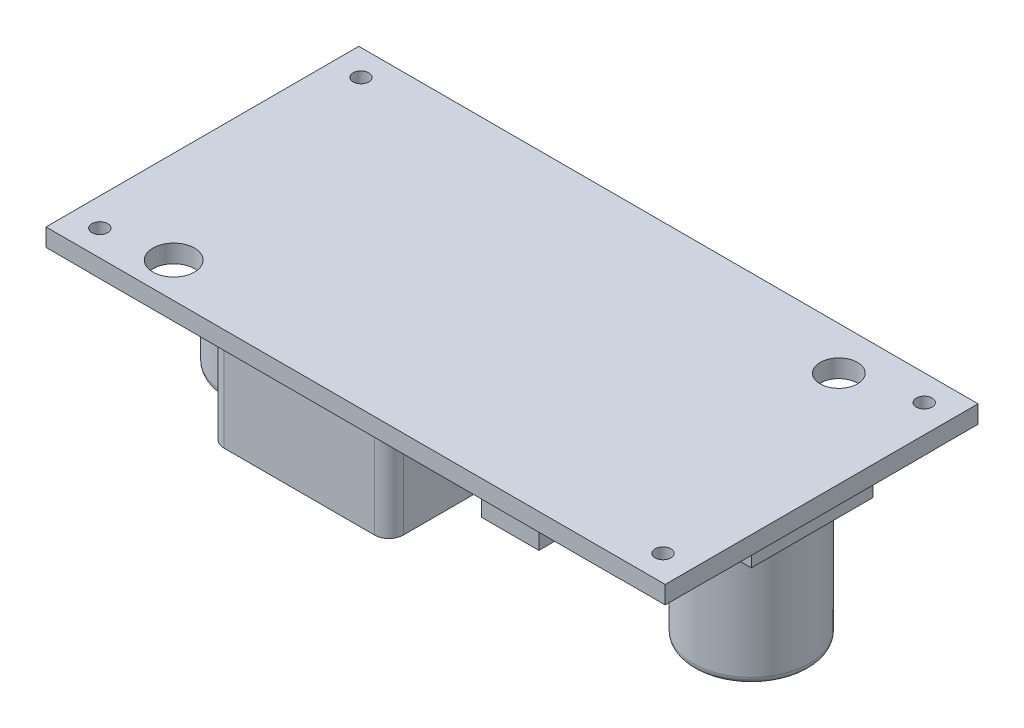
from build123d import *
from OCP.BRepFilletAPI import BRepFilletAPI_MakeChamfer

# Parameters (mm, degrees)
SKETCH1_W            = 43.15
SKETCH1_H            = 21.8
BOSS_EXTRUDE1_DEPTH  = 1.25
SKETCH2_R            = 0.55
CUT_EXTRUDE1_DEPTH   = 25.204403009
SKETCH3_R            = 1.3
SKETCH3_R_2          = 1.45
CUT_EXTRUDE2_DEPTH   = 25.204403009
SKETCH4_W            = 3
SKETCH4_H            = 3
CUT_EXTRUDE3_DEPTH   = 0.01
SKETCH5_W            = 0.089743589
SKETCH5_H            = 1
SKETCH5_W_2          = 0.384615385
SKETCH5_H_2          = 0.102564102
CUT_EXTRUDE4_DEPTH   = 0.01
SKETCH6_W            = 8.5
SKETCH6_H            = 8.5
BOSS_EXTRUDE2_DEPTH  = 1.75
SKETCH7_R            = 4.05
BOSS_EXTRUDE3_DEPTH  = 8.5
FILLET1_R            = 0.5
SKETCH8_W            = 12.5
SKETCH8_H            = 12.5
BOSS_EXTRUDE4_DEPTH  = 7.1
FILLET2_R            = 1
BOSS_EXTRUDE5_DEPTH  = 10
SKETCH10_W           = 4
SKETCH10_H           = 2.5
BOSS_EXTRUDE6_DEPTH  = 2.3
SKETCH11_W           = 10
SKETCH11_H           = 8.4
BOSS_EXTRUDE7_DEPTH  = 4.3
CHAMFER1_SIZE        = 2
CHAMFER1_SIZE2       = 0.727940469
SKETCH12_W           = 10
SKETCH12_H           = 1.5
BOSS_EXTRUDE8_DEPTH  = 1
SKETCH13_W           = 1
SKETCH13_H           = 5
BOSS_EXTRUDE9_DEPTH  = 1
LPATTERN1_COUNT      = 5
LPATTERN1_PITCH      = 1.9
SKETCH14_R           = 1.15
BOSS_EXTRUDE10_DEPTH = 1.6


with BuildPart() as part:
    # Sketch1 → Boss-Extrude1 (new body)
    with BuildSketch(Plane(origin=(0, 0, 0), x_dir=(1, 0, 0), z_dir=(0, 1, 0))):
        Rectangle(SKETCH1_W, SKETCH1_H)
    extrude(amount=BOSS_EXTRUDE1_DEPTH)

    # Sketch2 → Cut-Extrude1 (cut, through all)
    with BuildSketch(Plane(origin=(0, 1.25, 0), x_dir=(1, 0, 0), z_dir=(0, 1, 0))):
        with Locations(Location((19.625, 9.1, 0), (0, 0, 270))):
            Circle(SKETCH2_R)
        with Locations(Location((19.625, -9.1, 0), (0, 0, 270))):
            Circle(SKETCH2_R)
        with Locations(Location((-19.625, 9.1, 0), (0, 0, 270))):
            Circle(SKETCH2_R)
        with Locations(Location((-19.625, -9.1, 0), (0, 0, 270))):
            Circle(SKETCH2_R)
    extrude(amount=-CUT_EXTRUDE1_DEPTH, mode=Mode.SUBTRACT)

    # Sketch3 → Cut-Extrude2 (cut, through all)
    with BuildSketch(Plane(origin=(0, 1.25, 0), x_dir=(1, 0, 0), z_dir=(0, 1, 0))):
        with Locations(Location((14.875, 7.9, 0), (0, 0, 270))):
            Circle(SKETCH3_R)
        with Locations(Location((-15.125, -8.45, 0), (0, 0, 270))):
            Circle(SKETCH3_R_2)
    extrude(amount=-CUT_EXTRUDE2_DEPTH, mode=Mode.SUBTRACT)

    # Sketch4 → Cut-Extrude3 (cut)
    with BuildSketch(Plane.XZ):
        with Locations((20.075, -9.4)):
            Rectangle(SKETCH4_W, SKETCH4_H)
        with Locations((20.075, 9.4)):
            Rectangle(SKETCH4_W, SKETCH4_H)
        with Locations((-20.075, 9.4)):
            Rectangle(SKETCH4_W, SKETCH4_H)
        with Locations((-20.075, -9.4)):
            Rectangle(SKETCH4_W, SKETCH4_H)
    extrude(amount=-CUT_EXTRUDE3_DEPTH, mode=Mode.SUBTRACT)

    # Sketch5 → Cut-Extrude4 (cut)
    with BuildSketch(Plane.XZ):
        with Locations((20.573564305, -7.20434754)):
            Rectangle(SKETCH5_W, SKETCH5_H)
        Polygon((20.310743792, -6.70434754), (20.310743792, -7.70434754), (20.291913663, -7.70434754), (19.631256612, -6.917288246), (19.631256612, -7.70434754), (19.541513022, -7.70434754), (19.541513022, -6.70434754), (19.561945715, -6.70434754), (20.221000202, -7.489603951), (20.221000202, -6.70434754), align=None)
        Polygon((19.041513022, -7.242809079), (19.041513022, -7.537680874), (18.951769433, -7.537680874), (18.951769433, -7.242809079), (18.656897638, -7.242809079), (18.656897638, -7.153065489), (18.951769433, -7.153065489), (18.951769433, -6.858193694), (19.041513022, -6.858193694), (19.041513022, -7.153065489), (19.336384817, -7.153065489), (19.336384817, -7.242809079), align=None)
        with Locations((20.573564305, 7.050014745)):
            Rectangle(SKETCH5_W, SKETCH5_H)
        Polygon((20.310743792, 7.550014745), (20.310743792, 6.550014745), (20.291913663, 6.550014745), (19.631256612, 7.337074039), (19.631256612, 6.550014745), (19.541513022, 6.550014745), (19.541513022, 7.550014745), (19.561945715, 7.550014745), (20.221000202, 6.764758334), (20.221000202, 7.550014745), align=None)
        with Locations((19.182538664, 7.16539936)):
            Rectangle(SKETCH5_W_2, SKETCH5_H_2)
        with BuildLine():
            add(Edge.make_bspline(
                [(-18.368582224, -7.729988566), (-18.38710084, -7.729527463), (-18.423472932, -7.728621818), (-18.476879134, -7.721460512), (-18.528017723, -7.709673427), (-18.576919243, -7.693028676), (-18.623393505, -7.671446786), (-18.667587441, -7.645245887), (-18.709349143, -7.614168476), (-18.748570597, -7.578952276), (-18.784219107, -7.540242315), (-18.815239087, -7.498684445), (-18.841639984, -7.45511511), (-18.86321046, -7.409250571), (-18.880159794, -7.361295598), (-18.891849075, -7.310964515), (-18.89931763, -7.258591548), (-18.900190639, -7.222869536), (-18.900633506, -7.204748181)],
                knots=[0, 0, 0, 0, 1.065027606, 2.091802087, 3.093458616, 4.079833113, 5.057734272, 6.036020118, 7.030157768, 8.047461502, 9.064242947, 10.052216774, 11.02588392, 11.989864716, 12.962978571, 13.945936472, 14.957997893, 16, 16, 16, 16], degree=3))
            add(Edge.make_bspline(
                [(-18.900633506, -7.204748181), (-18.90019049, -7.186760417), (-18.899317256, -7.15130445), (-18.891843006, -7.099262352), (-18.880107666, -7.04924053), (-18.863420139, -7.001355329), (-18.841833774, -6.955583238), (-18.815391336, -6.911983419), (-18.784441048, -6.870304371), (-18.748938698, -6.831405973), (-18.710169843, -6.795754174), (-18.668868728, -6.764237449), (-18.625085193, -6.737982209), (-18.579502591, -6.716089273), (-18.531667274, -6.699508299), (-18.481916612, -6.687425442), (-18.429968515, -6.680032155), (-18.394581428, -6.679153244), (-18.376595044, -6.678706515)],
                knots=[0, 0, 0, 0, 1.043683505, 2.0572211, 3.045299494, 4.022276905, 4.994977706, 5.977452478, 6.97747046, 8.003698437, 9.029677512, 10.031249186, 11.013723958, 11.988083691, 12.9614021, 13.946617861, 14.956316495, 16, 16, 16, 16], degree=3))
            add(Edge.make_bspline(
                [(-18.376595044, -6.678706515), (-18.358473775, -6.679149137), (-18.322751929, -6.680021664), (-18.270313284, -6.687502917), (-18.219946351, -6.699197309), (-18.171806209, -6.715925718), (-18.125877061, -6.737463833), (-18.082163349, -6.763930978), (-18.040612543, -6.795118874), (-18.001647471, -6.830593343), (-17.966038663, -6.869287857), (-17.93471866, -6.910534742), (-17.908404103, -6.953941717), (-17.886856896, -6.99932985), (-17.869813875, -7.04658182), (-17.85818285, -7.09599486), (-17.850658584, -7.147292082), (-17.849791445, -7.182218594), (-17.849351454, -7.199940489)],
                knots=[0, 0, 0, 0, 1.053167129, 2.076072758, 3.073341244, 4.055601477, 5.033424535, 6.017524495, 7.021518915, 8.049444456, 9.077120685, 10.074910483, 11.055688766, 12.022980584, 12.991883888, 13.970269434, 14.970104079, 16, 16, 16, 16], degree=3))
            add(Edge.make_bspline(
                [(-17.849351454, -7.199940489), (-17.849504067, -7.211835592), (-17.849807368, -7.235475735), (-17.853464198, -7.270579678), (-17.858759817, -7.305122864), (-17.866388969, -7.338989175), (-17.876229927, -7.372184142), (-17.888357238, -7.404639879), (-17.902255142, -7.436623726), (-17.918802516, -7.467526974), (-17.936856197, -7.497398127), (-17.956541921, -7.525863672), (-17.977996948, -7.552415137), (-18.000914797, -7.577479162), (-18.025612702, -7.60062796), (-18.051718962, -7.622366229), (-18.079370174, -7.642468942), (-18.108610072, -7.660513888), (-18.138693172, -7.677088389), (-18.169837729, -7.690926734), (-18.201386624, -7.703157975), (-18.233617752, -7.712878184), (-18.266456557, -7.720613585), (-18.299944091, -7.725869594), (-18.334045863, -7.729534549), (-18.357020572, -7.729836576), (-18.368582224, -7.729988566)],
                knots=[0, 0, 0, 0, 1.037115869, 2.061148057, 3.07517727, 4.084041727, 5.086514338, 6.092668487, 7.104487461, 8.125783165, 9.147610153, 10.147694368, 11.141876323, 12.122903372, 13.107606018, 14.091946891, 15.084523921, 16.086505767, 17.087268121, 18.077809654, 19.05670789, 20.036870126, 21.011670792, 21.99694167, 22.991993299, 24, 24, 24, 24], degree=3))
        make_face()
        with BuildLine():
            add(Edge.make_bspline(
                [(-18.372989275, -7.627424463), (-18.363499236, -7.627309239), (-18.344609885, -7.627079893), (-18.316530705, -7.624040047), (-18.288810757, -7.619742766), (-18.26151094, -7.613485632), (-18.234606841, -7.605468265), (-18.208068597, -7.595567965), (-18.18187251, -7.584010035), (-18.156258128, -7.570593876), (-18.131634524, -7.555555754), (-18.107853744, -7.539700581), (-18.085824005, -7.522129706), (-18.065119795, -7.503494722), (-18.045791345, -7.483539051), (-18.027836073, -7.462409697), (-18.011271668, -7.440011003), (-17.996296681, -7.416436295), (-17.982970153, -7.391816886), (-17.971038343, -7.366623478), (-17.96114733, -7.340559972), (-17.953312174, -7.31378902), (-17.946661922, -7.286428592), (-17.942490391, -7.25832962), (-17.939421421, -7.229588972), (-17.939204674, -7.210165474), (-17.939095044, -7.20034113)],
                knots=[0, 0, 0, 0, 1.008431664, 2.007222653, 2.999229743, 3.989431819, 4.982149843, 5.98167215, 6.998687425, 8.024288174, 9.053028776, 10.065052016, 11.06063401, 12.045759335, 13.024701188, 14.011819507, 14.991481775, 15.984022113, 16.97831254, 17.965966747, 18.945551853, 19.938269878, 20.93007375, 21.936103907, 22.956087853, 24, 24, 24, 24], degree=3))
            add(Edge.make_bspline(
                [(-17.939095044, -7.20034113), (-17.939460124, -7.18589511), (-17.940178348, -7.157475319), (-17.946440049, -7.115822591), (-17.956161959, -7.075753585), (-17.970256891, -7.037507125), (-17.988237759, -7.000912661), (-18.010170767, -6.966112605), (-18.036256775, -6.933117223), (-18.065870762, -6.902172133), (-18.098252876, -6.873938567), (-18.132621434, -6.849121115), (-18.168704526, -6.828234054), (-18.206294178, -6.810772941), (-18.245711323, -6.797618465), (-18.286703235, -6.78823933), (-18.329270818, -6.782160446), (-18.35827816, -6.781570042), (-18.372989275, -6.781270617)],
                knots=[0, 0, 0, 0, 1.032022337, 2.030307203, 3.003823408, 3.974715386, 4.937372378, 5.913284036, 6.909147208, 7.938749767, 8.970518239, 9.975863271, 10.963918693, 11.946286286, 12.933361397, 13.927862637, 14.949112547, 16, 16, 16, 16], degree=3))
            add(Edge.make_bspline(
                [(-18.372989275, -6.781270617), (-18.382877743, -6.781406366), (-18.402489546, -6.781675596), (-18.43165912, -6.784391115), (-18.460305908, -6.788737028), (-18.488376886, -6.795025268), (-18.515909176, -6.802790779), (-18.542818434, -6.812424594), (-18.569100478, -6.823967656), (-18.594866621, -6.836852657), (-18.619558769, -6.851384521), (-18.642896516, -6.867351479), (-18.665033336, -6.884326002), (-18.685699755, -6.902826032), (-18.704947512, -6.922613368), (-18.722581883, -6.943832117), (-18.739138565, -6.966063017), (-18.754008519, -6.989631733), (-18.767517861, -7.014056337), (-18.779099158, -7.039323086), (-18.788995854, -7.065271951), (-18.79697217, -7.091928539), (-18.803226038, -7.119231138), (-18.807534348, -7.147219297), (-18.810548252, -7.175836215), (-18.810775408, -7.195191607), (-18.810889916, -7.204948502)],
                knots=[0, 0, 0, 0, 1.047362266, 2.077233941, 3.100744636, 4.115120168, 5.122788643, 6.129711893, 7.140355774, 8.162227187, 9.180148637, 10.17298275, 11.156396779, 12.133377858, 13.108923632, 14.078087502, 15.054351192, 16.043448276, 17.028082865, 18.009331763, 18.985518559, 19.968016174, 20.954783108, 21.950335389, 22.966780876, 24, 24, 24, 24], degree=3))
            add(Edge.make_bspline(
                [(-18.810889916, -7.204948502), (-18.810775312, -7.214638646), (-18.810547975, -7.233860832), (-18.807535839, -7.262278208), (-18.803221299, -7.29006484), (-18.797003382, -7.317111641), (-18.788989053, -7.343425506), (-18.779106957, -7.368981718), (-18.767454019, -7.393875494), (-18.754080225, -7.41804527), (-18.73904719, -7.441238137), (-18.722620051, -7.463409943), (-18.704516458, -7.484146175), (-18.685248916, -7.503951738), (-18.664354196, -7.522430498), (-18.641828634, -7.539510993), (-18.618233153, -7.555963051), (-18.593033905, -7.570522608), (-18.56712142, -7.584038293), (-18.54050506, -7.595559652), (-18.513517662, -7.605512241), (-18.48612318, -7.613451103), (-18.458368938, -7.619748844), (-18.430247222, -7.62403849), (-18.401768476, -7.627080219), (-18.382612784, -7.627309351), (-18.372989275, -7.627424463)],
                knots=[0, 0, 0, 0, 1.02988216, 2.042960975, 3.035124439, 4.018561492, 4.99104521, 5.957523397, 6.929462691, 7.91146347, 8.892205782, 9.866320947, 10.842813644, 11.816825305, 12.802668543, 13.805243666, 14.821427616, 15.858893029, 16.897256944, 17.927432741, 18.940436917, 19.95373962, 20.957947499, 21.96413624, 22.977215056, 24, 24, 24, 24], degree=3))
        make_face(mode=Mode.SUBTRACT)
        with BuildLine():
            Line((-19.105761711, -7.70434754), (-19.195505301, -7.70434754))
            Line((-19.195505301, -7.70434754), (-19.195505301, -7.105188887))
            add(Edge.make_bspline(
                [(-19.195505301, -7.105188887), (-19.195491945, -7.096708676), (-19.195466601, -7.080616016), (-19.195635891, -7.057710787), (-19.196109996, -7.037347228), (-19.196408899, -7.019446843), (-19.197073851, -7.004091772), (-19.19761615, -6.991198826), (-19.198313452, -6.980829054), (-19.199151486, -6.974777361), (-19.199511711, -6.972176066)],
                knots=[0, 0, 0, 0, 1.528628734, 2.90083645, 4.128790002, 5.200304208, 6.127813768, 6.898992206, 7.526736466, 8, 8, 8, 8], degree=3))
            add(Edge.make_bspline(
                [(-19.199511711, -6.972176066), (-19.200972681, -6.96271849), (-19.203793018, -6.944461064), (-19.211313216, -6.918494388), (-19.221256895, -6.894967818), (-19.233929246, -6.873618494), (-19.249558961, -6.854296305), (-19.268842928, -6.836815483), (-19.291741344, -6.821125667), (-19.317733544, -6.80736291), (-19.345445382, -6.795948363), (-19.373862777, -6.787403151), (-19.402442881, -6.782174425), (-19.421579401, -6.78157051), (-19.431082224, -6.781270617)],
                knots=[0, 0, 0, 0, 1.042923073, 2.013316119, 2.939979093, 3.821796737, 4.712412725, 5.640305549, 6.650442997, 7.732186751, 8.842579391, 9.91407549, 10.964170509, 12, 12, 12, 12], degree=3))
            add(Edge.make_bspline(
                [(-19.431082224, -6.781270617), (-19.439241167, -6.781575714), (-19.45551193, -6.782184145), (-19.479674294, -6.785998708), (-19.503282475, -6.792736533), (-19.526145917, -6.801919655), (-19.547912015, -6.813194438), (-19.567995575, -6.82679489), (-19.586185097, -6.842406149), (-19.602588639, -6.859955077), (-19.616866421, -6.879549214), (-19.629157428, -6.901086474), (-19.639199831, -6.924738634), (-19.644244776, -6.941407341), (-19.646827416, -6.949940489)],
                knots=[0, 0, 0, 0, 0.994543961, 1.983343699, 2.972712664, 3.980751554, 4.981834161, 5.954730495, 6.930176574, 7.89761099, 8.875938748, 9.87834379, 10.913868493, 12, 12, 12, 12], degree=3))
            add(Edge.make_bspline(
                [(-19.646827416, -6.949940489), (-19.647684595, -6.953468653), (-19.649594734, -6.961330825), (-19.651379604, -6.974622622), (-19.653238611, -6.990305297), (-19.654528488, -7.00849153), (-19.65578598, -7.029120379), (-19.656538286, -7.05229931), (-19.65688601, -7.077944156), (-19.656989633, -7.095840488), (-19.657043762, -7.105188887)],
                knots=[0, 0, 0, 0, 0.558680831, 1.244966039, 2.062412453, 2.990489873, 4.051219941, 5.244515665, 6.560634259, 8, 8, 8, 8], degree=3))
            Line((-19.657043762, -7.105188887), (-19.657043762, -7.70434754))
            Line((-19.657043762, -7.70434754), (-19.746787352, -7.70434754))
            Line((-19.746787352, -7.70434754), (-19.746787352, -7.100381194))
            add(Edge.make_bspline(
                [(-19.746787352, -7.100381194), (-19.746715538, -7.089495828), (-19.74657539, -7.068252374), (-19.745335645, -7.037125015), (-19.743415396, -7.007589937), (-19.740514726, -6.979684293), (-19.737305158, -6.95337668), (-19.732751804, -6.928763453), (-19.727909438, -6.905635808), (-19.721832335, -6.883951083), (-19.714603283, -6.863382087), (-19.705994517, -6.84354031), (-19.695509531, -6.824604275), (-19.683641199, -6.806226848), (-19.670146527, -6.788577391), (-19.655140581, -6.771518947), (-19.638383184, -6.755275772), (-19.620296672, -6.739770211), (-19.601027889, -6.725247988), (-19.580360656, -6.712883506), (-19.558664921, -6.702419257), (-19.536170782, -6.693506591), (-19.512498053, -6.686989185), (-19.487941602, -6.682096021), (-19.462328846, -6.679327946), (-19.444910587, -6.678915415), (-19.436090236, -6.678706515)],
                knots=[0, 0, 0, 0, 1.316485072, 2.56920066, 3.767172097, 4.895413872, 5.962239305, 6.971350037, 7.921780903, 8.819233545, 9.69278517, 10.557066787, 11.431700348, 12.307563454, 13.200791052, 14.11626757, 15.05287325, 16.020813301, 16.99640464, 17.967304965, 18.928075993, 19.907403966, 20.889159767, 21.893313923, 22.933205135, 24, 24, 24, 24], degree=3))
            add(Edge.make_bspline(
                [(-19.436090236, -6.678706515), (-19.426470423, -6.678930578), (-19.407596382, -6.679370189), (-19.379786501, -6.681893176), (-19.353121676, -6.686633269), (-19.327341664, -6.692707929), (-19.302695531, -6.700949216), (-19.279190538, -6.711075559), (-19.256556799, -6.722636319), (-19.235304248, -6.736297179), (-19.215258543, -6.751193427), (-19.19704158, -6.767555322), (-19.18019092, -6.78475972), (-19.165449304, -6.803454452), (-19.152259153, -6.823256821), (-19.14091112, -6.844259965), (-19.131163556, -6.86643573), (-19.126133233, -6.881851051), (-19.123590236, -6.889644015)],
                knots=[0, 0, 0, 0, 1.138939089, 2.234594419, 3.301501784, 4.342532435, 5.367382236, 6.373123747, 7.370098489, 8.372230273, 9.360297234, 10.323289009, 11.268038109, 12.20748145, 13.137029304, 14.081414587, 15.030090602, 16, 16, 16, 16], degree=3))
            add(Edge.make_bspline(
                [(-19.123590236, -6.889644015), (-19.122111048, -6.894967607), (-19.118902657, -6.906514599), (-19.115466857, -6.925625024), (-19.112578548, -6.947629286), (-19.109862674, -6.972528891), (-19.108260115, -7.000343139), (-19.106855132, -7.031059972), (-19.105751813, -7.064716533), (-19.105758319, -7.08816068), (-19.105761711, -7.100381194)],
                knots=[0, 0, 0, 0, 0.625038921, 1.35572334, 2.194682327, 3.136881307, 4.189498639, 5.346923369, 6.617055217, 8, 8, 8, 8], degree=3))
            Line((-19.105761711, -7.100381194), (-19.105761711, -7.70434754))
        make_face()
        Polygon((-19.900633506, -7.601783438), (-19.900633506, -7.70434754), (-20.426274531, -7.70434754), (-20.426274531, -7.601783438), (-20.208325813, -7.601783438), (-20.208325813, -6.70434754), (-20.118582224, -6.70434754), (-20.118582224, -7.601783438), align=None)
        Polygon((-20.849351454, -7.242809079), (-20.849351454, -7.537680874), (-20.939095044, -7.537680874), (-20.939095044, -7.242809079), (-21.233966839, -7.242809079), (-21.233966839, -7.153065489), (-20.939095044, -7.153065489), (-20.939095044, -6.858193694), (-20.849351454, -6.858193694), (-20.849351454, -7.153065489), (-20.554479659, -7.153065489), (-20.554479659, -7.242809079), align=None)
        with BuildLine():
            add(Edge.make_bspline(
                [(-18.368582224, 6.524373719), (-18.38710084, 6.524834822), (-18.423472932, 6.525740467), (-18.476879134, 6.532901773), (-18.528017723, 6.544688858), (-18.576919243, 6.561333609), (-18.623393505, 6.582915499), (-18.667587441, 6.609116398), (-18.709349143, 6.640193809), (-18.748570597, 6.675410009), (-18.784219107, 6.71411997), (-18.815239087, 6.75567784), (-18.841639984, 6.799247175), (-18.86321046, 6.845111714), (-18.880159794, 6.893066687), (-18.891849075, 6.94339777), (-18.89931763, 6.995770737), (-18.900190639, 7.031492749), (-18.900633506, 7.049614104)],
                knots=[0, 0, 0, 0, 1.065027606, 2.091802087, 3.093458616, 4.079833113, 5.057734272, 6.036020118, 7.030157768, 8.047461502, 9.064242947, 10.052216774, 11.02588392, 11.989864716, 12.962978571, 13.945936472, 14.957997893, 16, 16, 16, 16], degree=3))
            add(Edge.make_bspline(
                [(-18.900633506, 7.049614104), (-18.90019049, 7.067601868), (-18.899317256, 7.103057835), (-18.891843006, 7.155099933), (-18.880107666, 7.205121755), (-18.863420139, 7.253006955), (-18.841833774, 7.298779047), (-18.815391336, 7.342378866), (-18.784441048, 7.384057914), (-18.748938698, 7.422956312), (-18.710169843, 7.458608111), (-18.668868728, 7.490124836), (-18.625085193, 7.516380076), (-18.579502591, 7.538273012), (-18.531667274, 7.554853986), (-18.481916612, 7.566936843), (-18.429968515, 7.57433013), (-18.394581428, 7.575209041), (-18.376595044, 7.57565577)],
                knots=[0, 0, 0, 0, 1.043683505, 2.0572211, 3.045299494, 4.022276905, 4.994977706, 5.977452478, 6.97747046, 8.003698437, 9.029677512, 10.031249186, 11.013723958, 11.988083691, 12.9614021, 13.946617861, 14.956316495, 16, 16, 16, 16], degree=3))
            add(Edge.make_bspline(
                [(-18.376595044, 7.57565577), (-18.358473775, 7.575213148), (-18.322751929, 7.574340621), (-18.270313284, 7.566859368), (-18.219946351, 7.555164976), (-18.171806209, 7.538436567), (-18.125877061, 7.516898452), (-18.082163349, 7.490431307), (-18.040612543, 7.459243411), (-18.001647471, 7.423768942), (-17.966038663, 7.385074428), (-17.93471866, 7.343827542), (-17.908404103, 7.300420568), (-17.886856896, 7.255032435), (-17.869813875, 7.207780465), (-17.85818285, 7.158367425), (-17.850658584, 7.107070203), (-17.849791445, 7.072143691), (-17.849351454, 7.054421796)],
                knots=[0, 0, 0, 0, 1.053167129, 2.076072758, 3.073341244, 4.055601477, 5.033424535, 6.017524495, 7.021518915, 8.049444456, 9.077120685, 10.074910483, 11.055688766, 12.022980584, 12.991883888, 13.970269434, 14.970104079, 16, 16, 16, 16], degree=3))
            add(Edge.make_bspline(
                [(-17.849351454, 7.054421796), (-17.849504067, 7.042526693), (-17.849807368, 7.01888655), (-17.853464198, 6.983782607), (-17.858759817, 6.949239421), (-17.866388969, 6.91537311), (-17.876229927, 6.882178143), (-17.888357238, 6.849722406), (-17.902255142, 6.817738559), (-17.918802516, 6.786835311), (-17.936856197, 6.756964158), (-17.956541921, 6.728498613), (-17.977996948, 6.701947148), (-18.000914797, 6.676883123), (-18.025612702, 6.653734325), (-18.051718962, 6.631996056), (-18.079370174, 6.611893343), (-18.108610072, 6.593848397), (-18.138693172, 6.577273896), (-18.169837729, 6.563435551), (-18.201386624, 6.55120431), (-18.233617752, 6.541484101), (-18.266456557, 6.5337487), (-18.299944091, 6.528492691), (-18.334045863, 6.524827736), (-18.357020572, 6.524525709), (-18.368582224, 6.524373719)],
                knots=[0, 0, 0, 0, 1.037115869, 2.061148057, 3.07517727, 4.084041727, 5.086514338, 6.092668487, 7.104487461, 8.125783165, 9.147610153, 10.147694368, 11.141876323, 12.122903372, 13.107606018, 14.091946891, 15.084523921, 16.086505767, 17.087268121, 18.077809654, 19.05670789, 20.036870126, 21.011670792, 21.99694167, 22.991993299, 24, 24, 24, 24], degree=3))
        make_face()
        with BuildLine():
            add(Edge.make_bspline(
                [(-18.372989275, 6.626937821), (-18.363499236, 6.627053046), (-18.344609885, 6.627282392), (-18.316530705, 6.630322238), (-18.288810757, 6.634619519), (-18.26151094, 6.640876653), (-18.234606841, 6.64889402), (-18.208068597, 6.65879432), (-18.18187251, 6.67035225), (-18.156258128, 6.683768409), (-18.131634524, 6.698806531), (-18.107853744, 6.714661704), (-18.085824005, 6.732232579), (-18.065119795, 6.750867563), (-18.045791345, 6.770823234), (-18.027836073, 6.791952588), (-18.011271668, 6.814351282), (-17.996296681, 6.83792599), (-17.982970153, 6.862545399), (-17.971038343, 6.887738807), (-17.96114733, 6.913802313), (-17.953312174, 6.940573265), (-17.946661922, 6.967933693), (-17.942490391, 6.996032665), (-17.939421421, 7.024773313), (-17.939204674, 7.044196811), (-17.939095044, 7.054021155)],
                knots=[0, 0, 0, 0, 1.008431664, 2.007222653, 2.999229743, 3.989431819, 4.982149843, 5.98167215, 6.998687425, 8.024288174, 9.053028776, 10.065052016, 11.06063401, 12.045759335, 13.024701188, 14.011819507, 14.991481775, 15.984022113, 16.97831254, 17.965966747, 18.945551853, 19.938269878, 20.93007375, 21.936103907, 22.956087853, 24, 24, 24, 24], degree=3))
            add(Edge.make_bspline(
                [(-17.939095044, 7.054021155), (-17.939460124, 7.068467175), (-17.940178348, 7.096886966), (-17.946440049, 7.138539694), (-17.956161959, 7.1786087), (-17.970256891, 7.21685516), (-17.988237759, 7.253449624), (-18.010170767, 7.28824968), (-18.036256775, 7.321245062), (-18.065870762, 7.352190152), (-18.098252876, 7.380423718), (-18.132621434, 7.40524117), (-18.168704526, 7.426128231), (-18.206294178, 7.443589344), (-18.245711323, 7.45674382), (-18.286703235, 7.466122955), (-18.329270818, 7.472201839), (-18.35827816, 7.472792243), (-18.372989275, 7.473091668)],
                knots=[0, 0, 0, 0, 1.032022337, 2.030307203, 3.003823408, 3.974715386, 4.937372378, 5.913284036, 6.909147208, 7.938749767, 8.970518239, 9.975863271, 10.963918693, 11.946286286, 12.933361397, 13.927862637, 14.949112547, 16, 16, 16, 16], degree=3))
            add(Edge.make_bspline(
                [(-18.372989275, 7.473091668), (-18.382877743, 7.472955919), (-18.402489546, 7.472686689), (-18.43165912, 7.46997117), (-18.460305908, 7.465625257), (-18.488376886, 7.459337017), (-18.515909176, 7.451571506), (-18.542818434, 7.441937691), (-18.569100478, 7.430394629), (-18.594866621, 7.417509628), (-18.619558769, 7.402977764), (-18.642896516, 7.387010806), (-18.665033336, 7.370036283), (-18.685699755, 7.351536253), (-18.704947512, 7.331748917), (-18.722581883, 7.310530168), (-18.739138565, 7.288299268), (-18.754008519, 7.264730552), (-18.767517861, 7.240305948), (-18.779099158, 7.215039199), (-18.788995854, 7.189090334), (-18.79697217, 7.162433746), (-18.803226038, 7.135131147), (-18.807534348, 7.107142988), (-18.810548252, 7.07852607), (-18.810775408, 7.059170678), (-18.810889916, 7.049413783)],
                knots=[0, 0, 0, 0, 1.047362266, 2.077233941, 3.100744636, 4.115120168, 5.122788643, 6.129711893, 7.140355774, 8.162227187, 9.180148637, 10.17298275, 11.156396779, 12.133377858, 13.108923632, 14.078087502, 15.054351192, 16.043448276, 17.028082865, 18.009331763, 18.985518559, 19.968016174, 20.954783108, 21.950335389, 22.966780876, 24, 24, 24, 24], degree=3))
            add(Edge.make_bspline(
                [(-18.810889916, 7.049413783), (-18.810775312, 7.039723639), (-18.810547975, 7.020501453), (-18.807535839, 6.992084077), (-18.803221299, 6.964297445), (-18.797003382, 6.937250644), (-18.788989053, 6.910936779), (-18.779106957, 6.885380567), (-18.767454019, 6.860486791), (-18.754080225, 6.836317015), (-18.73904719, 6.813124148), (-18.722620051, 6.790952342), (-18.704516458, 6.77021611), (-18.685248916, 6.750410546), (-18.664354196, 6.731931787), (-18.641828634, 6.714851292), (-18.618233153, 6.698399234), (-18.593033905, 6.683839677), (-18.56712142, 6.670323992), (-18.54050506, 6.658802633), (-18.513517662, 6.648850044), (-18.48612318, 6.640911182), (-18.458368938, 6.634613441), (-18.430247222, 6.630323795), (-18.401768476, 6.627282066), (-18.382612784, 6.627052934), (-18.372989275, 6.626937821)],
                knots=[0, 0, 0, 0, 1.02988216, 2.042960975, 3.035124439, 4.018561492, 4.99104521, 5.957523397, 6.929462691, 7.91146347, 8.892205782, 9.866320947, 10.842813644, 11.816825305, 12.802668543, 13.805243666, 14.821427616, 15.858893029, 16.897256944, 17.927432741, 18.940436917, 19.95373962, 20.957947499, 21.96413624, 22.977215056, 24, 24, 24, 24], degree=3))
        make_face(mode=Mode.SUBTRACT)
        with BuildLine():
            Line((-19.105761711, 6.550014745), (-19.195505301, 6.550014745))
            Line((-19.195505301, 6.550014745), (-19.195505301, 7.149173398))
            add(Edge.make_bspline(
                [(-19.195505301, 7.149173398), (-19.195491945, 7.157653609), (-19.195466601, 7.173746269), (-19.195635891, 7.196651498), (-19.196109996, 7.217015057), (-19.196408899, 7.234915442), (-19.197073851, 7.250270513), (-19.19761615, 7.263163459), (-19.198313452, 7.273533231), (-19.199151486, 7.279584924), (-19.199511711, 7.282186219)],
                knots=[0, 0, 0, 0, 1.528628734, 2.90083645, 4.128790002, 5.200304208, 6.127813768, 6.898992206, 7.526736466, 8, 8, 8, 8], degree=3))
            add(Edge.make_bspline(
                [(-19.199511711, 7.282186219), (-19.200972681, 7.291643795), (-19.203793018, 7.309901221), (-19.211313216, 7.335867897), (-19.221256895, 7.359394467), (-19.233929246, 7.380743791), (-19.249558961, 7.40006598), (-19.268842928, 7.417546802), (-19.291741344, 7.433236618), (-19.317733544, 7.446999375), (-19.345445382, 7.458413922), (-19.373862777, 7.466959134), (-19.402442881, 7.47218786), (-19.421579401, 7.472791775), (-19.431082224, 7.473091668)],
                knots=[0, 0, 0, 0, 1.042923073, 2.013316119, 2.939979093, 3.821796737, 4.712412725, 5.640305549, 6.650442997, 7.732186751, 8.842579391, 9.91407549, 10.964170509, 12, 12, 12, 12], degree=3))
            add(Edge.make_bspline(
                [(-19.431082224, 7.473091668), (-19.439241167, 7.472786571), (-19.45551193, 7.47217814), (-19.479674294, 7.468363577), (-19.503282475, 7.461625751), (-19.526145917, 7.45244263), (-19.547912015, 7.441167847), (-19.567995575, 7.427567395), (-19.586185097, 7.411956136), (-19.602588639, 7.394407208), (-19.616866421, 7.374813071), (-19.629157428, 7.353275811), (-19.639199831, 7.329623651), (-19.644244776, 7.312954944), (-19.646827416, 7.304421796)],
                knots=[0, 0, 0, 0, 0.994543961, 1.983343699, 2.972712664, 3.980751554, 4.981834161, 5.954730495, 6.930176574, 7.89761099, 8.875938748, 9.87834379, 10.913868493, 12, 12, 12, 12], degree=3))
            add(Edge.make_bspline(
                [(-19.646827416, 7.304421796), (-19.647684595, 7.300893632), (-19.649594734, 7.29303146), (-19.651379604, 7.279739663), (-19.653238611, 7.264056988), (-19.654528488, 7.245870755), (-19.65578598, 7.225241906), (-19.656538286, 7.202062975), (-19.65688601, 7.176418129), (-19.656989633, 7.158521797), (-19.657043762, 7.149173398)],
                knots=[0, 0, 0, 0, 0.558680831, 1.244966039, 2.062412453, 2.990489873, 4.051219941, 5.244515665, 6.560634259, 8, 8, 8, 8], degree=3))
            Line((-19.657043762, 7.149173398), (-19.657043762, 6.550014745))
            Line((-19.657043762, 6.550014745), (-19.746787352, 6.550014745))
            Line((-19.746787352, 6.550014745), (-19.746787352, 7.153981091))
            add(Edge.make_bspline(
                [(-19.746787352, 7.153981091), (-19.746715538, 7.164866457), (-19.74657539, 7.186109911), (-19.745335645, 7.21723727), (-19.743415396, 7.246772348), (-19.740514726, 7.274677992), (-19.737305158, 7.300985605), (-19.732751804, 7.325598832), (-19.727909438, 7.348726477), (-19.721832335, 7.370411202), (-19.714603283, 7.390980198), (-19.705994517, 7.410821975), (-19.695509531, 7.42975801), (-19.683641199, 7.448135437), (-19.670146527, 7.465784894), (-19.655140581, 7.482843338), (-19.638383184, 7.499086513), (-19.620296672, 7.514592074), (-19.601027889, 7.529114297), (-19.580360656, 7.541478779), (-19.558664921, 7.551943028), (-19.536170782, 7.560855694), (-19.512498053, 7.5673731), (-19.487941602, 7.572266264), (-19.462328846, 7.575034339), (-19.444910587, 7.57544687), (-19.436090236, 7.57565577)],
                knots=[0, 0, 0, 0, 1.316485072, 2.56920066, 3.767172097, 4.895413872, 5.962239305, 6.971350037, 7.921780903, 8.819233545, 9.69278517, 10.557066787, 11.431700348, 12.307563454, 13.200791052, 14.11626757, 15.05287325, 16.020813301, 16.99640464, 17.967304965, 18.928075993, 19.907403966, 20.889159767, 21.893313923, 22.933205135, 24, 24, 24, 24], degree=3))
            add(Edge.make_bspline(
                [(-19.436090236, 7.57565577), (-19.426470423, 7.575431707), (-19.407596382, 7.574992096), (-19.379786501, 7.572469109), (-19.353121676, 7.567729016), (-19.327341664, 7.561654356), (-19.302695531, 7.553413069), (-19.279190538, 7.543286726), (-19.256556799, 7.531725966), (-19.235304248, 7.518065106), (-19.215258543, 7.503168858), (-19.19704158, 7.486806963), (-19.18019092, 7.469602565), (-19.165449304, 7.450907833), (-19.152259153, 7.431105464), (-19.14091112, 7.41010232), (-19.131163556, 7.387926555), (-19.126133233, 7.372511233), (-19.123590236, 7.36471827)],
                knots=[0, 0, 0, 0, 1.138939089, 2.234594419, 3.301501784, 4.342532435, 5.367382236, 6.373123747, 7.370098489, 8.372230273, 9.360297234, 10.323289009, 11.268038109, 12.20748145, 13.137029304, 14.081414587, 15.030090602, 16, 16, 16, 16], degree=3))
            add(Edge.make_bspline(
                [(-19.123590236, 7.36471827), (-19.122111048, 7.359394678), (-19.118902657, 7.347847686), (-19.115466857, 7.328737261), (-19.112578548, 7.306732999), (-19.109862674, 7.281833394), (-19.108260115, 7.254019146), (-19.106855132, 7.223302313), (-19.105751813, 7.189645752), (-19.105758319, 7.166201605), (-19.105761711, 7.153981091)],
                knots=[0, 0, 0, 0, 0.625038921, 1.35572334, 2.194682327, 3.136881307, 4.189498639, 5.346923369, 6.617055217, 8, 8, 8, 8], degree=3))
            Line((-19.105761711, 7.153981091), (-19.105761711, 6.550014745))
        make_face()
        Polygon((-19.900633506, 6.652578847), (-19.900633506, 6.550014745), (-20.426274531, 6.550014745), (-20.426274531, 6.652578847), (-20.208325813, 6.652578847), (-20.208325813, 7.550014745), (-20.118582224, 7.550014745), (-20.118582224, 6.652578847), align=None)
        with Locations((-20.708325814, 7.16539936)):
            Rectangle(SKETCH5_W_2, SKETCH5_H_2)
    extrude(amount=-CUT_EXTRUDE4_DEPTH, mode=Mode.SUBTRACT)

    # Sketch6 → Boss-Extrude2 (add)
    with BuildSketch(Plane.XZ):
        with Locations((16.325, -0.35)):
            Rectangle(SKETCH6_W, SKETCH6_H)
        with Locations((-16.325, -0.35)):
            Rectangle(SKETCH6_W, SKETCH6_H)
    extrude(amount=BOSS_EXTRUDE2_DEPTH)

    # Sketch7 → Boss-Extrude3 (add)
    with BuildSketch(Plane.XZ.offset(1.75)):
        with Locations(Location((-16.325, -0.35, 0), (0, 0, 270))):
            Circle(SKETCH7_R)
        with Locations(Location((16.325, -0.35, 0), (0, 0, 270))):
            Circle(SKETCH7_R)
    extrude(amount=BOSS_EXTRUDE3_DEPTH)

    # Fillet1
    fillet1_edges = [part.edges().sort_by_distance(p)[0] for p in [
        (-16.325, -10.25, 3.7),
        (16.325, -10.25, 3.7),
    ]]
    fillet(fillet1_edges, radius=FILLET1_R)

    # Sketch8 → Boss-Extrude4 (add)
    with BuildSketch(Plane.XZ):
        with Locations((-5.125, 3.45)):
            Rectangle(SKETCH8_W, SKETCH8_H)
    extrude(amount=BOSS_EXTRUDE4_DEPTH)

    # Fillet2
    fillet2_edges = [part.edges().sort_by_distance(p)[0] for p in [
        (-11.375, -3.55, 9.7),
        (-11.375, -3.55, -2.8),
        (1.125, -3.55, -2.8),
        (1.125, -3.55, 9.7),
    ]]
    fillet(fillet2_edges, radius=FILLET2_R)

    # Sketch9 → Boss-Extrude5 (add)
    with BuildSketch(Plane.XZ):
        Polygon((-10.225, -4.5), (-10.225, -5.2), (-2.125, -5.2), (-2.125, -4.5), (-1.425, -4.5), (-1.425, -9.5), (-10.925, -9.5), (-10.925, -4.5), align=None)
    extrude(amount=BOSS_EXTRUDE5_DEPTH)

    # Sketch10 → Boss-Extrude6 (add)
    with BuildSketch(Plane.XZ):
        with Locations((9.575, 8.45)):
            Rectangle(SKETCH10_W, SKETCH10_H)
    extrude(amount=BOSS_EXTRUDE6_DEPTH)

    # Sketch11 → Boss-Extrude7 (add)
    with BuildSketch(Plane.XZ):
        with Locations((6.625, -3.6)):
            Rectangle(SKETCH11_W, SKETCH11_H)
    extrude(amount=BOSS_EXTRUDE7_DEPTH)

    # Chamfer1: one chamfer whose edges measure the first distance from different faces: ONE call of the kernel's chamfer builder (chamfer() names one face for all edges)
    chamfer1_edges_1 = [part.edges().sort_by_distance(p)[0] for p in [
        (6.625, -4.3, -7.8),
    ]]
    chamfer1_side_1 = [part.faces().sort_by_distance(p)[0] for p in [
        (6.625, -2.15, -7.8),
    ]]
    chamfer1_edges_2 = [part.edges().sort_by_distance(p)[0] for p in [
        (6.625, -4.3, 0.6),
    ]]
    chamfer1_side_2 = [part.faces().sort_by_distance(p)[0] for p in [
        (6.625, -2.15, 0.6),
    ]]
    chamfer1 = BRepFilletAPI_MakeChamfer(part.part.solid().wrapped)
    for e in chamfer1_edges_1:
        chamfer1.Add(CHAMFER1_SIZE, CHAMFER1_SIZE2, e.wrapped, chamfer1_side_1[0].wrapped)  # the first distance lies on this face
    for e in chamfer1_edges_2:
        chamfer1.Add(CHAMFER1_SIZE, CHAMFER1_SIZE2, e.wrapped, chamfer1_side_2[0].wrapped)  # the first distance lies on this face
    add(Compound.cast(chamfer1.Shape()), mode=Mode.REPLACE)

    # Sketch12 → Boss-Extrude8 (add)
    with BuildSketch(Plane.XZ):
        with Locations((6.625, -8.55)):
            Rectangle(SKETCH12_W, SKETCH12_H)
    extrude(amount=BOSS_EXTRUDE8_DEPTH)

    # Sketch13 → Boss-Extrude9 (add)
    with BuildSketch(Plane.XZ):
        with Locations((2.875, 3.1)):
            Rectangle(SKETCH13_W, SKETCH13_H)
    boss_extrude9 = extrude(amount=BOSS_EXTRUDE9_DEPTH)

    # LPattern1: Boss-Extrude9 ×5
    with Locations(*[(i * LPATTERN1_PITCH, 0, 0) for i in range(1, LPATTERN1_COUNT)]):
        add(boss_extrude9)

    # Sketch14 → Boss-Extrude10 (add)
    with BuildSketch(Plane.XZ.offset(10)):
        with Locations((-2.575, -8.2)):
            Circle(SKETCH14_R)
    extrude(amount=BOSS_EXTRUDE10_DEPTH)


solid = part.part
